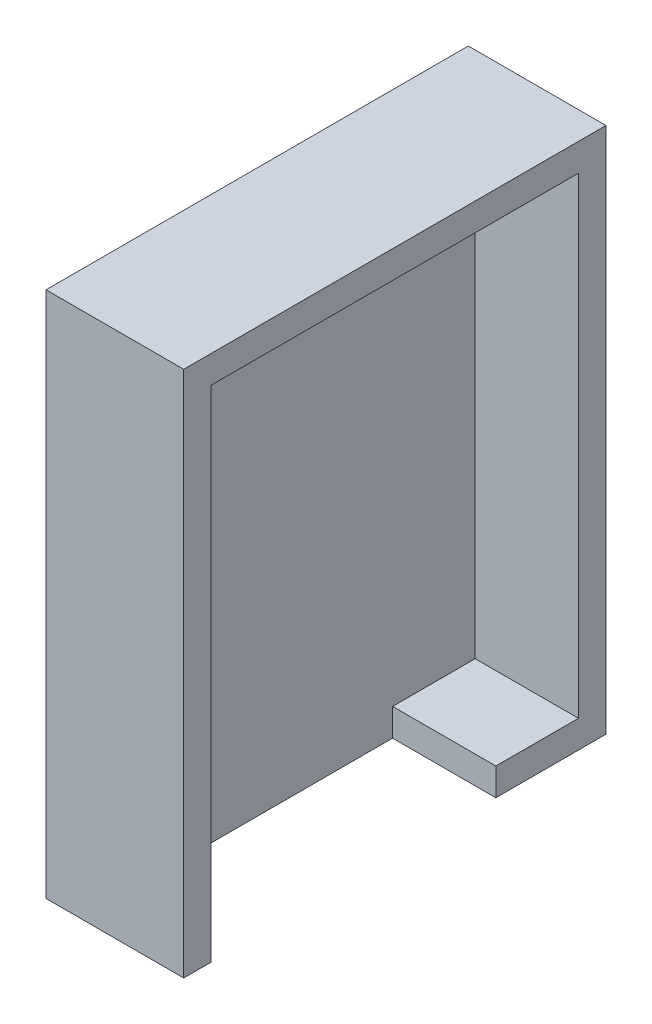
from build123d import *

# Parameters (mm, degrees)
SKETCH1_W           = 61.34
SKETCH1_H           = 76.58
SKETCH1_W_2         = 53.34
SKETCH1_H_2         = 68.58
BOSS_EXTRUDE1_DEPTH = 15
SKETCH2_W           = 61.34
SKETCH2_H           = 76.58
BOSS_EXTRUDE2_DEPTH = 5
SKETCH4_W           = 19.05
SKETCH4_H           = 53.34
CUT_EXTRUDE2_DEPTH  = 21
SKETCH5_W           = 12
SKETCH5_H           = 4
BOSS_EXTRUDE3_DEPTH = 15


with BuildPart() as part:
    # Sketch1 → Boss-Extrude1 (new body)
    with BuildSketch(Plane(origin=(0, 0, 0), x_dir=(0, 0, -1), z_dir=(1, 0, 0))):
        with Locations((26.67, -34.29)):
            Rectangle(SKETCH1_W, SKETCH1_H)
        with Locations((26.67, -34.29)):
            Rectangle(SKETCH1_W_2, SKETCH1_H_2, mode=Mode.SUBTRACT)
    extrude(amount=BOSS_EXTRUDE1_DEPTH)

    # Sketch2 → Boss-Extrude2 (add)
    with BuildSketch(Plane.ZY):
        with Locations((-26.67, -34.29)):
            Rectangle(SKETCH2_W, SKETCH2_H)
    extrude(amount=BOSS_EXTRUDE2_DEPTH)

    # Sketch4 → Cut-Extrude2 (cut)
    with BuildSketch(Plane(origin=(0, -72.58, 0), x_dir=(-1, 0, 0), z_dir=(0, -1, 0))):
        with Locations((-9.525, 26.67)):
            Rectangle(SKETCH4_W, SKETCH4_H)
    extrude(amount=-CUT_EXTRUDE2_DEPTH, mode=Mode.SUBTRACT)

    # Sketch5 → Boss-Extrude3 (add)
    with BuildSketch(Plane(origin=(0, 0, 0), x_dir=(0, 0, -1), z_dir=(1, 0, 0))):
        with Locations((47.34, -70.58)):
            Rectangle(SKETCH5_W, SKETCH5_H)
    extrude(amount=BOSS_EXTRUDE3_DEPTH)


solid = part.part
